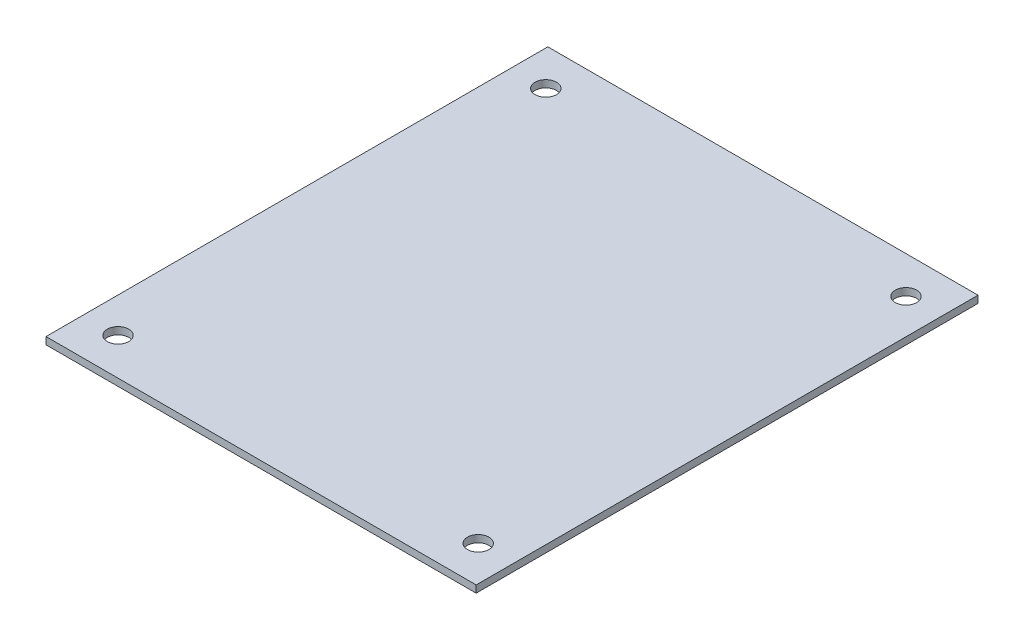
from build123d import *

# Parameters (mm, degrees)
SKETCH1_W           = 60
SKETCH1_H           = 70
BOSS_EXTRUDE1_DEPTH = 1
SKETCH2_R           = 1.5
CUT_EXTRUDE1_DEPTH  = 1


with BuildPart() as part:
    # Sketch1 → Boss-Extrude1 (new body)
    with BuildSketch(Plane(origin=(0, 0, 0), x_dir=(1, 0, 0), z_dir=(0, 1, 0))):
        Rectangle(SKETCH1_W, SKETCH1_H)
    extrude(amount=BOSS_EXTRUDE1_DEPTH)

    # Sketch2 → Cut-Extrude1 (cut)
    with BuildSketch(Plane(origin=(0, 1, 0), x_dir=(1, 0, 0), z_dir=(0, 1, 0))):
        with Locations((-25.119291996, 29.832609661)):
            Circle(SKETCH2_R)
        with Locations((-25.119291996, -29.832609661)):
            Circle(SKETCH2_R)
        with Locations((25.119291996, 29.832609661)):
            Circle(SKETCH2_R)
        with Locations((25.119291996, -29.832609661)):
            Circle(SKETCH2_R)
    extrude(amount=-CUT_EXTRUDE1_DEPTH, mode=Mode.SUBTRACT)


solid = part.part
